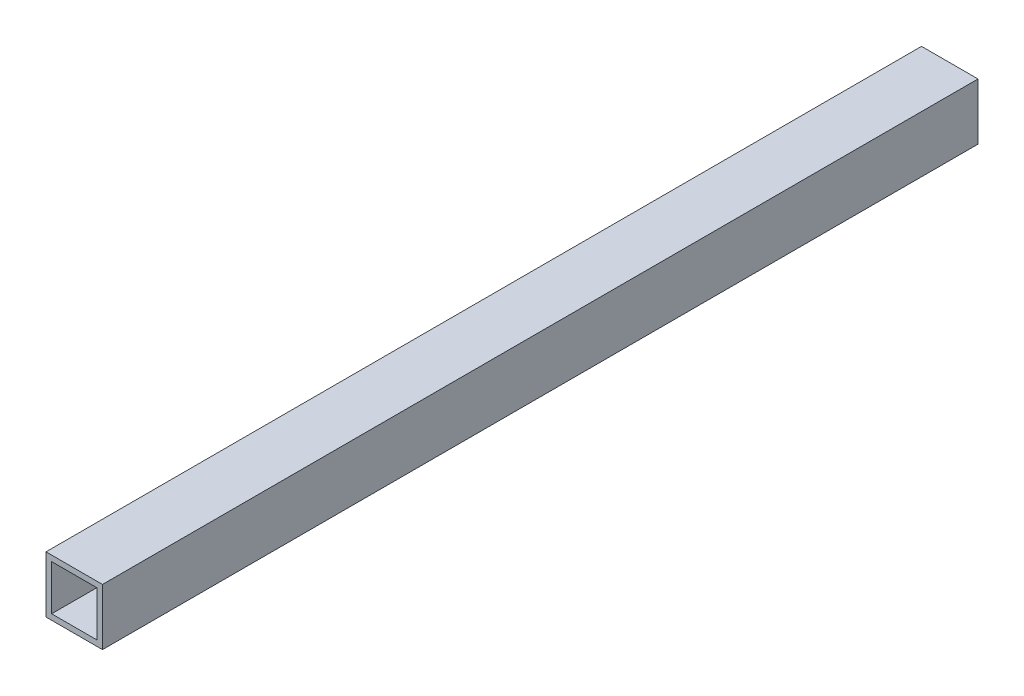
from build123d import *

# Parameters (mm, degrees)
SKETCH1_W   = 40
SKETCH1_H   = 40
SKETCH1_W_2 = 32
SKETCH1_H_2 = 32


with BuildPart() as part:
    # Sweep1: sweep along a curve in space
    with BuildLine() as sweep1_path:
        add(Edge.make_bspline(
            [(0, 0, 0), (0, 0, 620)],
            knots=[0, 0, 1, 1], degree=1))
    # Sketch1 → Sweep1 (sweep)
    with BuildSketch(Plane.XY):
        Rectangle(SKETCH1_W, SKETCH1_H)
        Rectangle(SKETCH1_W_2, SKETCH1_H_2, mode=Mode.SUBTRACT)
    sweep(path=sweep1_path.line)


solid = part.part
